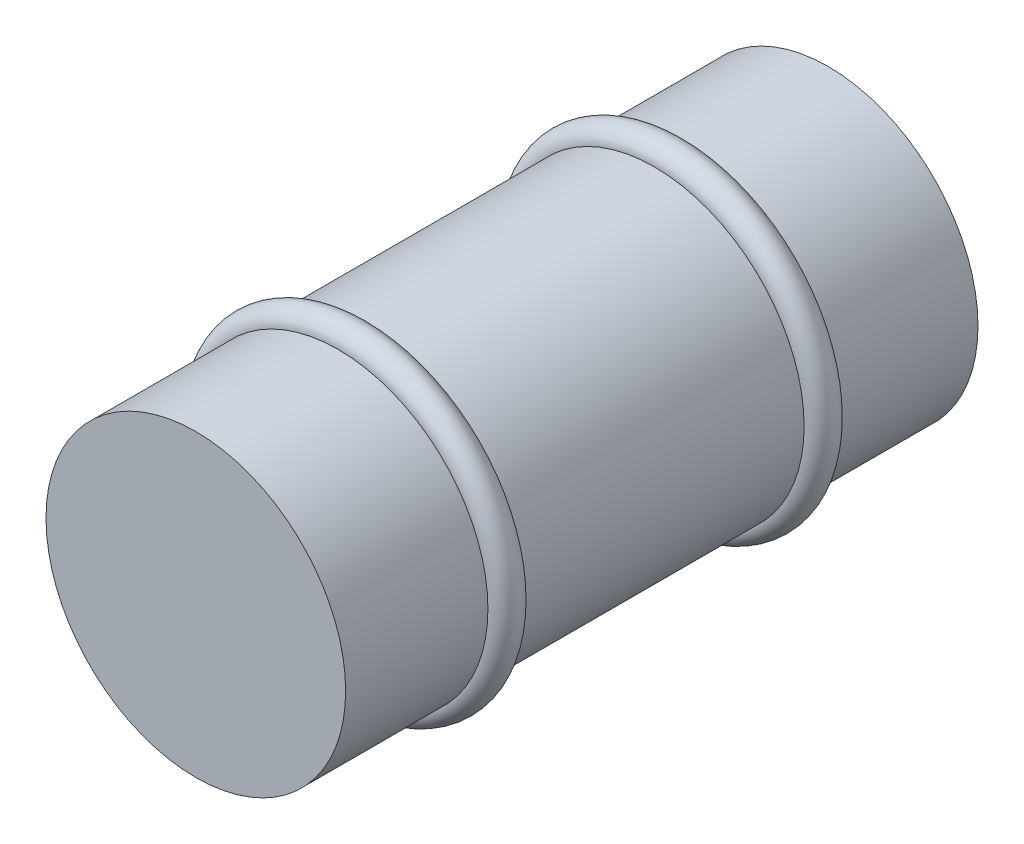
from build123d import *

# Parameters (mm, degrees)
SKETCH1_R           = 23.692946145
BOSS_EXTRUDE1_DEPTH = 100
SKETCH4_R           = 2.5
SKETCH5_R           = 2.5
LPATTERN1_COUNT     = 2
LPATTERN1_PITCH     = 50


with BuildPart() as part:
    # Sketch1 → Boss-Extrude1 (new body)
    with BuildSketch(Plane.XY):
        Circle(SKETCH1_R)
    extrude(amount=BOSS_EXTRUDE1_DEPTH)

    # Cut-Sweep1: sweep along a path in Sketch3
    with BuildLine(Plane.XY.offset(75)) as cut_sweep1_path:
        CenterArc((0, 0), 23.692946145, 0, 360)
    # Sketch4 → Cut-Sweep1 (sweep, cut)
    with BuildSketch(Plane(origin=(23.607658585, 0, 75), x_dir=(1, 0, 0), z_dir=(0, 1, 0))):
        with Locations((0.08528756, 0)):
            Circle(SKETCH4_R)
    sweep(path=cut_sweep1_path.line, mode=Mode.SUBTRACT)


with BuildPart() as body_2:
    # Sweep1: sweep along a path in Sketch3_2
    with BuildLine(Plane.XY.offset(75)) as sweep1_path:
        CenterArc((0, 0), 23.692946145, 0, 360)
    # Sketch5 → Sweep1 (sweep)
    with BuildSketch(Plane(origin=(23.607658585, 0, 75), x_dir=(1, 0, 0), z_dir=(0, 1, 0))):
        with Locations((0.08528756, 0)):
            Circle(SKETCH5_R)
    sweep(path=sweep1_path.line)


with BuildPart() as lpattern1_1:
    # LPattern1: pattern copy
    add(body_2.part.moved(Location(Vector(0, 0, -1) * (1 * LPATTERN1_PITCH))))


solid = Compound([part.part, body_2.part, lpattern1_1.part])
